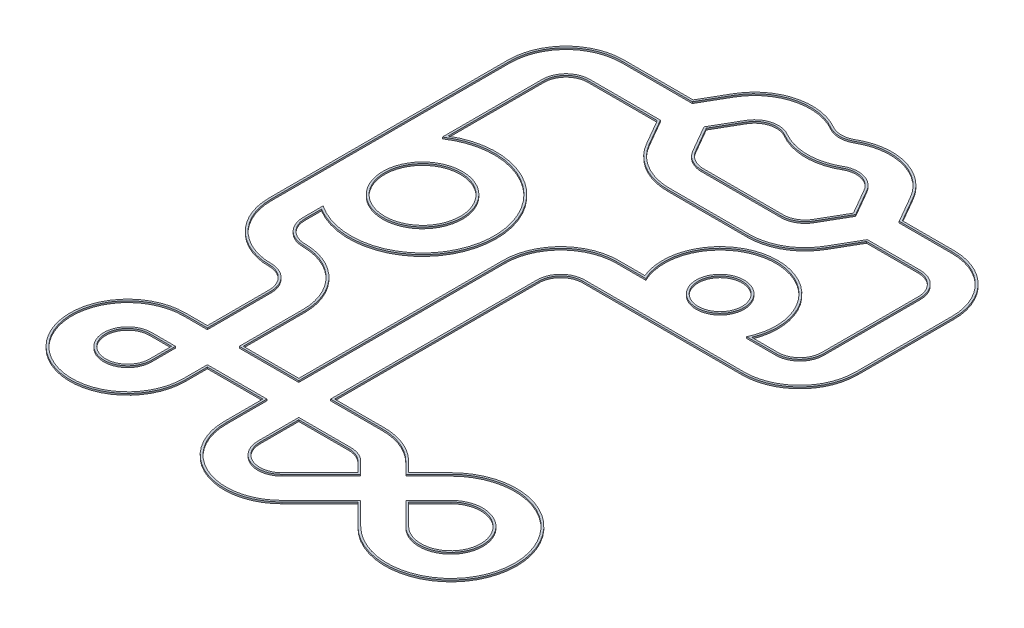
from build123d import *

# Parameters (mm, degrees)
EXTRUDE_2_DEPTH   = 20
EXTRUDE_2_2_DEPTH = 20
EXTRUDE_2_3_DEPTH = 20
EXTRUDE_2_4_DEPTH = 20
EXTRUDE_2_5_DEPTH = 20
EXTRUDE_2_6_DEPTH = 20
EXTRUDE_2_7_DEPTH = 20
EXTRUDE_2_8_DEPTH = 20


with BuildPart() as part:
    # 草图1 → 凸台-拉伸2 (new body)
    with BuildSketch(Plane(origin=(0, 0, 0), x_dir=(1, 0, 0), z_dir=(0, 1, 0))):
        with BuildLine():
            Line((1730.940107676, 500), (1923.205080757, 833.012701892))
            ThreePointArc((1923.205080757, 833.012701892), (2105.366988361, 972.790449779), (2333.012701892, 942.820323028))
            ThreePointArc((2333.012701892, 942.820323028), (2683.012701892, 849.038105677), (3033.012701892, 942.820323028))
            ThreePointArc((3033.012701892, 942.820323028), (3260.658415423, 972.790449779), (3442.820323028, 833.012701892))
            Line((3442.820323028, 833.012701892), (3635.085296109, 500))
            Line((3635.085296109, 500), (3442.820323028, 166.987298108))
            ThreePointArc((3442.820323028, 166.987298108), (3333.012701893, 57.179676972), (3183.012701893, 16.987298108))
            Line((3183.012701893, 16.987298108), (2183.012701892, 16.987298108))
            ThreePointArc((2183.012701892, 16.987298108), (2033.012701892, 57.179676972), (1923.205080757, 166.987298108))
            Line((1923.205080757, 166.987298108), (1730.940107676, 500))
        make_face()
        with BuildLine():
            Line((3421.169687933, 820.512701892), (3606.217782649, 500))
            Line((3606.217782649, 500), (3421.169687933, 179.487298108))
            ThreePointArc((3421.169687933, 179.487298108), (3320.512701893, 78.830312067), (3183.012701893, 41.987298108))
            Line((3183.012701893, 41.987298108), (2183.012701892, 41.987298108))
            ThreePointArc((2183.012701892, 41.987298108), (2045.512701892, 78.830312067), (1944.855715851, 179.487298108))
            Line((1944.855715851, 179.487298108), (1759.807621135, 500))
            Line((1759.807621135, 500), (1944.855715851, 820.512701892))
            ThreePointArc((1944.855715851, 820.512701892), (2111.837464489, 948.642304122), (2320.512701892, 921.169687933))
            ThreePointArc((2320.512701892, 921.169687933), (2683.012701892, 824.038105677), (3045.512701892, 921.169687933))
            ThreePointArc((3045.512701892, 921.169687933), (3254.187939295, 948.642304122), (3421.169687933, 820.512701892))
        make_face(mode=Mode.SUBTRACT)
    extrude(amount=EXTRUDE_2_DEPTH)


with BuildPart() as body_2:
    # 草图1 → Extrude 2 2 (new body)
    with BuildSketch(Plane(origin=(0, 0, 0), x_dir=(1, 0, 0), z_dir=(0, 1, 0))):
        with BuildLine():
            Line((1384.529946162, 300), (1576.794919243, -33.012701892))
            ThreePointArc((1576.794919243, -33.012701892), (1833.012701892, -289.230484541), (2183.012701892, -383.012701892))
            Line((2183.012701892, -383.012701892), (3183.012701893, -383.012701892))
            ThreePointArc((3183.012701893, -383.012701892), (3533.012701893, -289.230484541), (3789.230484542, -33.012701892))
            Line((3789.230484542, -33.012701892), (3981.495457623, 300))
            Line((3981.495457623, 300), (4646.446609407, 300))
            ThreePointArc((4646.446609407, 300), (4858.578643763, 212.132034356), (4946.446609407, 0))
            Line((4946.446609407, 0), (4946.446609407, -1212.132034356))
            ThreePointArc((4946.446609407, -1212.132034356), (4858.578643763, -1424.264068712), (4646.446609407, -1512.132034356))
            Line((4646.446609407, -1512.132034356), (4278.90214144, -1512.132034356))
            ThreePointArc((4278.90214144, -1512.132034356), (4238.054587717, -837.966295679), (3646.446609407, -512.132034356))
            ThreePointArc((3646.446609407, -512.132034356), (3054.838631097, -837.966295679), (3013.991077373, -1512.132034356))
            Line((3013.991077373, -1512.132034356), (2646.446609407, -1512.132034356))
            ThreePointArc((2646.446609407, -1512.132034356), (2151.471862576, -1717.157287525), (1946.446609407, -2212.132034356))
            Line((1946.446609407, -2212.132034356), (1946.446609407, -4800))
            Line((1946.446609407, -4800), (1200, -4800))
            Line((1200, -4800), (1200, -4000))
            ThreePointArc((1200, -4000), (994.974746831, -3505.025253169), (500, -3300))
            ThreePointArc((500, -3300), (287.867965644, -3212.132034356), (200, -3000))
            Line((200, -3000), (200, -2748.331477355))
            ThreePointArc((200, -2748.331477355), (1124.264068712, -2793.725393319), (1600, -2000))
            ThreePointArc((1600, -2000), (1124.264068712, -1206.274606681), (200, -1251.668522645))
            Line((200, -1251.668522645), (200, 0))
            ThreePointArc((200, 0), (287.867965644, 212.132034356), (500, 300))
            Line((500, 300), (1384.529946162, 300))
        make_face()
        with BuildLine():
            Line((4646.446609407, -1487.132034356), (4317.267002657, -1487.132034356))
            ThreePointArc((4317.267002657, -1487.132034356), (4248.526338346, -808.244673821), (3646.446609407, -487.132034356))
            ThreePointArc((3646.446609407, -487.132034356), (3044.366880467, -808.244673821), (2975.626216157, -1487.132034356))
            Line((2975.626216157, -1487.132034356), (2646.446609407, -1487.132034356))
            ThreePointArc((2646.446609407, -1487.132034356), (2133.794193046, -1699.479617996), (1921.446609407, -2212.132034356))
            Line((1921.446609407, -2212.132034356), (1921.446609407, -4775))
            Line((1921.446609407, -4775), (1225, -4775))
            Line((1225, -4775), (1225, -4000))
            ThreePointArc((1225, -4000), (1012.65241636, -3487.34758364), (500, -3275))
            ThreePointArc((500, -3275), (305.545635174, -3194.454364826), (225, -3000))
            Line((225, -3000), (225, -2793.725393319))
            ThreePointArc((225, -2793.725393319), (1156.207189772, -2804.673846972), (1625, -2000))
            ThreePointArc((1625, -2000), (1156.207189772, -1195.326153028), (225, -1206.274606681))
            Line((225, -1206.274606681), (225, 0))
            ThreePointArc((225, 0), (305.545635174, 194.454364826), (500, 275))
            Line((500, 275), (1370.096189432, 275))
            Line((1370.096189432, 275), (1555.144284149, -45.512701892))
            ThreePointArc((1555.144284149, -45.512701892), (1820.512701892, -310.881119636), (2183.012701892, -408.012701892))
            Line((2183.012701892, -408.012701892), (3183.012701893, -408.012701892))
            ThreePointArc((3183.012701893, -408.012701892), (3545.512701893, -310.881119636), (3810.881119636, -45.512701892))
            Line((3810.881119636, -45.512701892), (3995.929214352, 275))
            Line((3995.929214352, 275), (4646.446609407, 275))
            ThreePointArc((4646.446609407, 275), (4840.900974233, 194.454364826), (4921.446609407, 0))
            Line((4921.446609407, 0), (4921.446609407, -1212.132034356))
            ThreePointArc((4921.446609407, -1212.132034356), (4840.900974233, -1406.586399182), (4646.446609407, -1487.132034356))
        make_face(mode=Mode.SUBTRACT)
    extrude(amount=EXTRUDE_2_2_DEPTH)


with BuildPart() as body_3:
    # 草图1 → Extrude 2 3 (new body)
    with BuildSketch(Plane(origin=(0, 0, 0), x_dir=(1, 0, 0), z_dir=(0, 1, 0))):
        with BuildLine():
            Line((2858.578643763, -5924.264068712), (3353.553390593, -5429.289321881))
            Line((3353.553390593, -5429.289321881), (3212.132034356, -5287.867965644))
            ThreePointArc((3212.132034356, -5287.867965644), (3114.80502971, -5222.836140247), (3000, -5200))
            Line((3000, -5200), (2346.446609407, -5200))
            Line((2346.446609407, -5200), (2346.446609407, -5712.132034356))
            ThreePointArc((2346.446609407, -5712.132034356), (2531.641579697, -5989.295894109), (2858.578643763, -5924.264068712))
        make_face()
        with BuildLine():
            Line((2840.900974233, -5906.586399182), (3318.198051534, -5429.289321881))
            Line((3318.198051534, -5429.289321881), (3194.454364826, -5305.545635174))
            ThreePointArc((3194.454364826, -5305.545635174), (3105.2379439, -5245.933128559), (3000, -5225))
            Line((3000, -5225), (2371.446609407, -5225))
            Line((2371.446609407, -5225), (2371.446609407, -5712.132034356))
            ThreePointArc((2371.446609407, -5712.132034356), (2541.208665506, -5966.198905797), (2840.900974233, -5906.586399182))
        make_face(mode=Mode.SUBTRACT)
    extrude(amount=EXTRUDE_2_3_DEPTH)


with BuildPart() as body_4:
    # 草图1 → Extrude 2 4 (new body)
    with BuildSketch(Plane(origin=(0, 0, 0), x_dir=(1, 0, 0), z_dir=(0, 1, 0))):
        with BuildLine():
            Line((4202.081528017, -5712.132034356), (3919.238815543, -5429.289321881))
            Line((3919.238815543, -5429.289321881), (4202.081528017, -5146.446609407))
            ThreePointArc((4202.081528017, -5146.446609407), (4884.924240492, -5429.289321881), (4202.081528017, -5712.132034356))
        make_face()
        with BuildLine():
            Line((4219.759197547, -5694.454364826), (3954.594154602, -5429.289321881))
            Line((3954.594154602, -5429.289321881), (4219.759197547, -5164.124278936))
            ThreePointArc((4219.759197547, -5164.124278936), (4859.924240492, -5429.289321881), (4219.759197547, -5694.454364826))
        make_face(mode=Mode.SUBTRACT)
    extrude(amount=EXTRUDE_2_4_DEPTH)


with BuildPart() as body_5:
    # 草图1 → Extrude 2 5 (new body)
    with BuildSketch(Plane(origin=(0, 0, 0), x_dir=(1, 0, 0), z_dir=(0, 1, 0))):
        with BuildLine():
            Line((800, -5500), (800, -5200))
            Line((800, -5200), (500, -5200))
            ThreePointArc((500, -5200), (287.867965644, -5712.132034356), (800, -5500))
        make_face()
        with BuildLine():
            Line((775, -5500), (775, -5225))
            Line((775, -5225), (500, -5225))
            ThreePointArc((500, -5225), (305.545635174, -5694.454364826), (775, -5500))
        make_face(mode=Mode.SUBTRACT)
    extrude(amount=EXTRUDE_2_5_DEPTH)


with BuildPart() as body_6:
    # 草图1 → Extrude 2 6 (new body)
    with BuildSketch(Plane(origin=(0, 0, 0), x_dir=(1, 0, 0), z_dir=(0, 1, 0))):
        with BuildLine():
            Line((4646.446609407, -1937.132034356), (3646.446609407, -1937.132034356))
            Line((3646.446609407, -1937.132034356), (2646.446609407, -1937.132034356))
            ThreePointArc((2646.446609407, -1937.132034356), (2451.99224458, -2017.67766953), (2371.446609407, -2212.132034356))
            Line((2371.446609407, -2212.132034356), (2371.446609407, -4775))
            Line((2371.446609407, -4775), (3000, -4775))
            ThreePointArc((3000, -4775), (3277.445488465, -4830.187338929), (3512.65241636, -4987.34758364))
            Line((3512.65241636, -4987.34758364), (3636.396103068, -5111.091270347))
            Line((3636.396103068, -5111.091270347), (3901.561146013, -4845.926227402))
            ThreePointArc((3901.561146013, -4845.926227402), (5309.924240492, -5429.289321881), (3901.561146013, -6012.65241636))
            Line((3901.561146013, -6012.65241636), (3636.396103068, -5747.487373415))
            Line((3636.396103068, -5747.487373415), (3159.099025767, -6224.784450716))
            ThreePointArc((3159.099025767, -6224.784450716), (2369.001120942, -6381.944695427), (1921.446609407, -5712.132034356))
            Line((1921.446609407, -5712.132034356), (1921.446609407, -5225))
            Line((1921.446609407, -5225), (1225, -5225))
            Line((1225, -5225), (1225, -5500))
            ThreePointArc((1225, -5500), (-12.65241636, -6012.65241636), (500, -4775))
            Line((500, -4775), (775, -4775))
            Line((775, -4775), (775, -4000))
            ThreePointArc((775, -4000), (694.454364826, -3805.545635174), (500, -3725))
            ThreePointArc((500, -3725), (-12.65241636, -3512.65241636), (-225, -3000))
            Line((-225, -3000), (-225, -2000))
            Line((-225, -2000), (-225, 0))
            ThreePointArc((-225, 0), (-12.65241636, 512.65241636), (500, 725))
            Line((500, 725), (1370.096189432, 725))
            Line((1370.096189432, 725), (1555.144284148, 1045.512701892))
            ThreePointArc((1555.144284148, 1045.512701892), (1995.368894193, 1383.308925952), (2545.512701892, 1310.881119636))
            ThreePointArc((2545.512701892, 1310.881119636), (2683.012701892, 1274.038105677), (2820.512701892, 1310.881119636))
            ThreePointArc((2820.512701892, 1310.881119636), (3370.656509592, 1383.308925952), (3810.881119636, 1045.512701892))
            Line((3810.881119636, 1045.512701892), (3995.929214352, 725))
            Line((3995.929214352, 725), (4646.446609407, 725))
            ThreePointArc((4646.446609407, 725), (5159.099025767, 512.65241636), (5371.446609407, 0))
            Line((5371.446609407, 0), (5371.446609407, -1212.132034356))
            ThreePointArc((5371.446609407, -1212.132034356), (5159.099025767, -1724.784450716), (4646.446609407, -1937.132034356))
        make_face()
        with BuildLine():
            Line((500, 700), (1384.529946162, 700))
            Line((1384.529946162, 700), (1576.794919243, 1033.012701892))
            ThreePointArc((1576.794919243, 1033.012701892), (2001.83937032, 1359.160780295), (2533.012701892, 1289.230484541))
            ThreePointArc((2533.012701892, 1289.230484541), (2683.012701892, 1249.038105677), (2833.012701892, 1289.230484541))
            ThreePointArc((2833.012701892, 1289.230484541), (3364.186033464, 1359.160780295), (3789.230484541, 1033.012701892))
            Line((3789.230484541, 1033.012701892), (3981.495457623, 700))
            Line((3981.495457623, 700), (4646.446609407, 700))
            ThreePointArc((4646.446609407, 700), (5141.421356237, 494.974746831), (5346.446609407, 0))
            Line((5346.446609407, 0), (5346.446609407, -1212.132034356))
            ThreePointArc((5346.446609407, -1212.132034356), (5141.421356237, -1707.106781187), (4646.446609407, -1912.132034356))
            Line((4646.446609407, -1912.132034356), (3646.446609407, -1912.132034356))
            Line((3646.446609407, -1912.132034356), (2646.446609407, -1912.132034356))
            ThreePointArc((2646.446609407, -1912.132034356), (2434.314575051, -2000), (2346.446609407, -2212.132034356))
            Line((2346.446609407, -2212.132034356), (2346.446609407, -4800))
            Line((2346.446609407, -4800), (3000, -4800))
            ThreePointArc((3000, -4800), (3267.878402656, -4853.284327242), (3494.974746831, -5005.025253169))
            Line((3494.974746831, -5005.025253169), (3636.396103068, -5146.446609407))
            Line((3636.396103068, -5146.446609407), (3919.238815543, -4863.603896932))
            ThreePointArc((3919.238815543, -4863.603896932), (5284.924240492, -5429.289321881), (3919.238815543, -5994.974746831))
            Line((3919.238815543, -5994.974746831), (3636.396103068, -5712.132034356))
            Line((3636.396103068, -5712.132034356), (3141.421356237, -6207.106781187))
            ThreePointArc((3141.421356237, -6207.106781187), (2378.568206751, -6358.847707114), (1946.446609407, -5712.132034356))
            Line((1946.446609407, -5712.132034356), (1946.446609407, -5200))
            Line((1946.446609407, -5200), (1200, -5200))
            Line((1200, -5200), (1200, -5500))
            ThreePointArc((1200, -5500), (5.025253169, -5994.974746831), (500, -4800))
            Line((500, -4800), (800, -4800))
            Line((800, -4800), (800, -4000))
            ThreePointArc((800, -4000), (712.132034356, -3787.867965644), (500, -3700))
            ThreePointArc((500, -3700), (5.025253169, -3494.974746831), (-200, -3000))
            Line((-200, -3000), (-200, -2000))
            Line((-200, -2000), (-200, 0))
            ThreePointArc((-200, 0), (5.025253169, 494.974746831), (500, 700))
        make_face(mode=Mode.SUBTRACT)
    extrude(amount=EXTRUDE_2_6_DEPTH)


with BuildPart() as body_7:
    # 草图1 → Extrude 2 7 (new body)
    with BuildSketch(Plane(origin=(0, 0, 0), x_dir=(1, 0, 0), z_dir=(0, 1, 0))):
        with BuildLine():
            ThreePointArc((3646.446609407, -1512.132034356), (3346.446609407, -1212.132034356), (3646.446609407, -912.132034356))
            ThreePointArc((3646.446609407, -912.132034356), (3946.446609407, -1212.132034356), (3646.446609407, -1512.132034356))
        make_face()
        with BuildLine():
            ThreePointArc((3646.446609407, -1487.132034356), (3371.446609407, -1212.132034356), (3646.446609407, -937.132034356))
            ThreePointArc((3646.446609407, -937.132034356), (3921.446609407, -1212.132034356), (3646.446609407, -1487.132034356))
        make_face(mode=Mode.SUBTRACT)
    extrude(amount=EXTRUDE_2_7_DEPTH)


with BuildPart() as body_8:
    # 草图1 → Extrude 2 8 (new body)
    with BuildSketch(Plane(origin=(0, 0, 0), x_dir=(1, 0, 0), z_dir=(0, 1, 0))):
        with BuildLine():
            ThreePointArc((1200, -2000), (700, -2500), (200, -2000))
            ThreePointArc((200, -2000), (700, -1500), (1200, -2000))
        make_face()
        with BuildLine():
            ThreePointArc((225, -2000), (700, -1525), (1175, -2000))
            ThreePointArc((1175, -2000), (700, -2475), (225, -2000))
        make_face(mode=Mode.SUBTRACT)
    extrude(amount=EXTRUDE_2_8_DEPTH)


solid = Compound([part.part, body_2.part, body_3.part, body_4.part, body_5.part, body_6.part, body_7.part, body_8.part])
